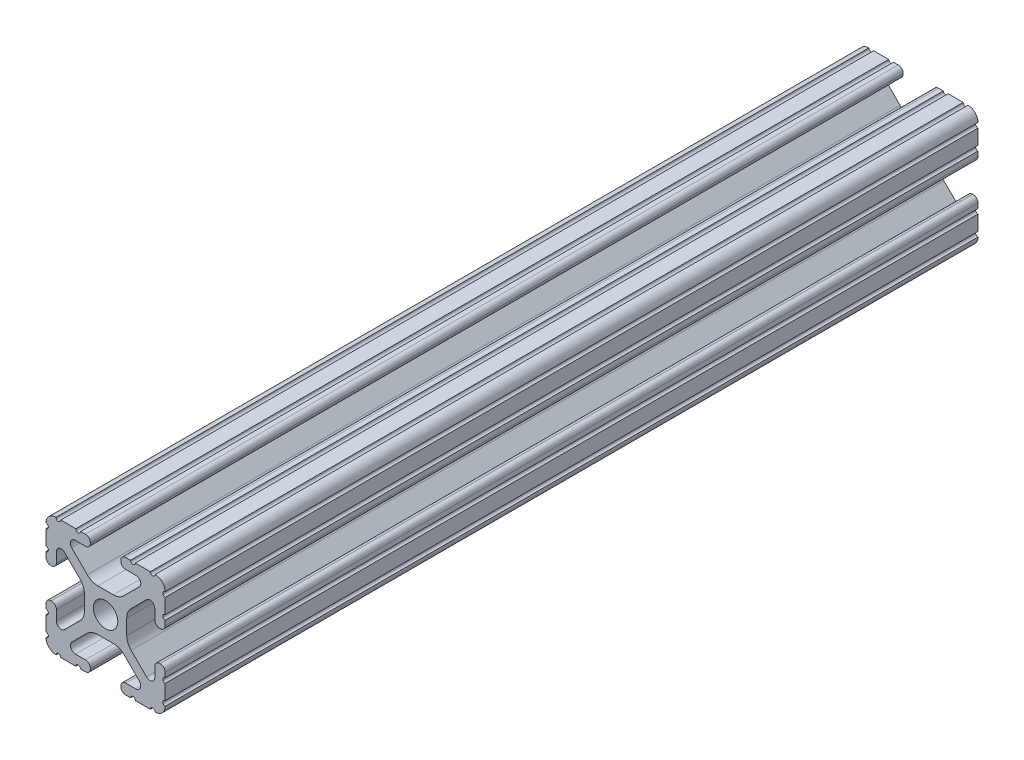
from build123d import *

# Parameters (mm, degrees)
SKETCH1_R           = 2.6035
BOSS_EXTRUDE1_DEPTH = 86.64956


with BuildPart() as part:
    # Sketch1 → Boss-Extrude1 (new body, symmetric)
    with BuildSketch(Plane.XY):
        with BuildLine():
            Line((-7.179650497, -8.645192506), (-3.952270251, -5.423690499))
            ThreePointArc((-3.952270251, -5.423690499), (-2.922936451, -4.736929036), (-1.709253557, -4.4958))
            Line((-1.709253557, -4.4958), (1.709253557, -4.4958))
            ThreePointArc((1.709253557, -4.4958), (2.922936451, -4.736929036), (3.952270251, -5.423690499))
            Line((3.952270251, -5.423690499), (7.179650497, -8.645192506))
            ThreePointArc((7.179650497, -8.645192506), (7.41473083, -9.822813117), (6.416408329, -10.4902))
            Line((6.416408329, -10.4902), (4.287512407, -10.4902))
            ThreePointArc((4.287512407, -10.4902), (3.54574862, -10.79744862), (3.2385, -11.539212407))
            Line((3.2385, -11.539212407), (3.2385, -11.650987593))
            ThreePointArc((3.2385, -11.650987593), (3.54574862, -12.39275138), (4.287512407, -12.7))
            Line((4.287512407, -12.7), (5.317126718, -12.7))
            ThreePointArc((5.317126718, -12.7), (5.825126718, -12.192), (6.333126718, -12.7))
            Line((6.333126718, -12.7), (9.550443118, -12.7))
            ThreePointArc((9.550443118, -12.7), (10.058366869, -12.192000006), (10.566443095, -12.699847501))
            ThreePointArc((10.566443095, -12.699847501), (12.082537762, -12.08250727), (12.699846982, -10.566399977))
            ThreePointArc((12.699846982, -10.566399977), (12.192000006, -10.058323491), (12.7, -9.5504))
            Line((12.7, -9.5504), (12.7, -6.3330836))
            ThreePointArc((12.7, -6.3330836), (12.192, -5.8250836), (12.7, -5.3170836))
            Line((12.7, -5.3170836), (12.7, -4.287469289))
            ThreePointArc((12.7, -4.287469289), (12.39275138, -3.545705502), (11.650987593, -3.238456882))
            Line((11.650987593, -3.238456882), (11.539212407, -3.238456882))
            ThreePointArc((11.539212407, -3.238456882), (10.79744862, -3.545705502), (10.4902, -4.287469289))
            Line((10.4902, -4.287469289), (10.4902, -6.402089023))
            ThreePointArc((10.4902, -6.402089023), (9.856505071, -7.351067942), (8.737131347, -7.129408934))
            Line((8.737131347, -7.129408934), (5.441005833, -3.840816462))
            ThreePointArc((5.441005833, -3.840816462), (4.750877967, -2.809883091), (4.5085, -1.593185507))
            Line((4.5085, -1.593185507), (4.5085, 1.593185507))
            ThreePointArc((4.5085, 1.593185507), (4.750877967, 2.809883091), (5.441005833, 3.840816462))
            Line((5.441005833, 3.840816462), (8.737131347, 7.129408934))
            ThreePointArc((8.737131347, 7.129408934), (9.856505071, 7.351067942), (10.4902, 6.402089023))
            Line((10.4902, 6.402089023), (10.4902, 4.287469289))
            ThreePointArc((10.4902, 4.287469289), (10.79744862, 3.545705502), (11.539212407, 3.238456882))
            Line((11.539212407, 3.238456882), (11.650987593, 3.238456882))
            ThreePointArc((11.650987593, 3.238456882), (12.39275138, 3.545705502), (12.7, 4.287469289))
            Line((12.7, 4.287469289), (12.7, 5.3170836))
            ThreePointArc((12.7, 5.3170836), (12.192, 5.8250836), (12.7, 6.3330836))
            Line((12.7, 6.3330836), (12.7, 9.5504))
            ThreePointArc((12.7, 9.5504), (12.192000006, 10.058323491), (12.699846982, 10.566399977))
            ThreePointArc((12.699846982, 10.566399977), (12.082537762, 12.08250727), (10.566443095, 12.699847501))
            ThreePointArc((10.566443095, 12.699847501), (10.058366869, 12.192000006), (9.550443118, 12.7))
            Line((9.550443118, 12.7), (6.333126718, 12.7))
            ThreePointArc((6.333126718, 12.7), (5.825126718, 12.192), (5.317126718, 12.7))
            Line((5.317126718, 12.7), (4.287512407, 12.7))
            ThreePointArc((4.287512407, 12.7), (3.54574862, 12.39275138), (3.2385, 11.650987593))
            Line((3.2385, 11.650987593), (3.2385, 11.539212407))
            ThreePointArc((3.2385, 11.539212407), (3.54574862, 10.79744862), (4.287512407, 10.4902))
            Line((4.287512407, 10.4902), (6.476788598, 10.4902))
            ThreePointArc((6.476788598, 10.4902), (7.432222385, 9.85140422), (7.207036008, 8.724370562))
            Line((7.207036008, 8.724370562), (3.898272566, 5.423169045))
            ThreePointArc((3.898272566, 5.423169045), (2.869120213, 4.736787962), (1.655778399, 4.4958))
            Line((1.655778399, 4.4958), (-1.655778399, 4.4958))
            ThreePointArc((-1.655778399, 4.4958), (-2.869120213, 4.736787962), (-3.898272566, 5.423169045))
            Line((-3.898272566, 5.423169045), (-7.207036008, 8.724370562))
            ThreePointArc((-7.207036008, 8.724370562), (-7.432222385, 9.85140422), (-6.476788598, 10.4902))
            Line((-6.476788598, 10.4902), (-4.287512407, 10.4902))
            ThreePointArc((-4.287512407, 10.4902), (-3.54574862, 10.79744862), (-3.2385, 11.539212407))
            Line((-3.2385, 11.539212407), (-3.2385, 11.650987593))
            ThreePointArc((-3.2385, 11.650987593), (-3.54574862, 12.39275138), (-4.287512407, 12.7))
            Line((-4.287512407, 12.7), (-5.317126718, 12.7))
            ThreePointArc((-5.317126718, 12.7), (-5.825126718, 12.192), (-6.333126718, 12.7))
            Line((-6.333126718, 12.7), (-9.550443118, 12.7))
            ThreePointArc((-9.550443118, 12.7), (-10.058366869, 12.192000006), (-10.566443095, 12.699847501))
            ThreePointArc((-10.566443095, 12.699847501), (-12.082537762, 12.08250727), (-12.699846982, 10.566399977))
            ThreePointArc((-12.699846982, 10.566399977), (-12.192000006, 10.058323491), (-12.7, 9.5504))
            Line((-12.7, 9.5504), (-12.7, 6.3330836))
            ThreePointArc((-12.7, 6.3330836), (-12.192, 5.8250836), (-12.7, 5.3170836))
            Line((-12.7, 5.3170836), (-12.7, 4.287469289))
            ThreePointArc((-12.7, 4.287469289), (-12.39275138, 3.545705502), (-11.650987593, 3.238456882))
            Line((-11.650987593, 3.238456882), (-11.539212407, 3.238456882))
            ThreePointArc((-11.539212407, 3.238456882), (-10.79744862, 3.545705502), (-10.4902, 4.287469289))
            Line((-10.4902, 4.287469289), (-10.4902, 6.402089023))
            ThreePointArc((-10.4902, 6.402089023), (-9.856505071, 7.351067942), (-8.737131347, 7.129408934))
            Line((-8.737131347, 7.129408934), (-5.441005833, 3.840816462))
            ThreePointArc((-5.441005833, 3.840816462), (-4.750877967, 2.809883091), (-4.5085, 1.593185507))
            Line((-4.5085, 1.593185507), (-4.5085, -1.593185507))
            ThreePointArc((-4.5085, -1.593185507), (-4.750877967, -2.809883091), (-5.441005833, -3.840816462))
            Line((-5.441005833, -3.840816462), (-8.737131347, -7.129408934))
            ThreePointArc((-8.737131347, -7.129408934), (-9.856505071, -7.351067942), (-10.4902, -6.402089023))
            Line((-10.4902, -6.402089023), (-10.4902, -4.287469289))
            ThreePointArc((-10.4902, -4.287469289), (-10.79744862, -3.545705502), (-11.539212407, -3.238456882))
            Line((-11.539212407, -3.238456882), (-11.650987593, -3.238456882))
            ThreePointArc((-11.650987593, -3.238456882), (-12.39275138, -3.545705502), (-12.7, -4.287469289))
            Line((-12.7, -4.287469289), (-12.7, -5.3170836))
            ThreePointArc((-12.7, -5.3170836), (-12.192, -5.8250836), (-12.7, -6.3330836))
            Line((-12.7, -6.3330836), (-12.7, -9.5504))
            ThreePointArc((-12.7, -9.5504), (-12.192000006, -10.058323491), (-12.699846982, -10.566399977))
            ThreePointArc((-12.699846982, -10.566399977), (-12.082537762, -12.08250727), (-10.566443095, -12.699847501))
            ThreePointArc((-10.566443095, -12.699847501), (-10.058366869, -12.192000006), (-9.550443118, -12.7))
            Line((-9.550443118, -12.7), (-6.333126718, -12.7))
            ThreePointArc((-6.333126718, -12.7), (-5.825126718, -12.192), (-5.317126718, -12.7))
            Line((-5.317126718, -12.7), (-4.287512407, -12.7))
            ThreePointArc((-4.287512407, -12.7), (-3.54574862, -12.39275138), (-3.2385, -11.650987593))
            Line((-3.2385, -11.650987593), (-3.2385, -11.539212407))
            ThreePointArc((-3.2385, -11.539212407), (-3.54574862, -10.79744862), (-4.287512407, -10.4902))
            Line((-4.287512407, -10.4902), (-6.416408329, -10.4902))
            ThreePointArc((-6.416408329, -10.4902), (-7.41473083, -9.822813117), (-7.179650497, -8.645192506))
        make_face()
        Circle(SKETCH1_R, mode=Mode.SUBTRACT)
    extrude(amount=BOSS_EXTRUDE1_DEPTH, both=True)


solid = part.part
